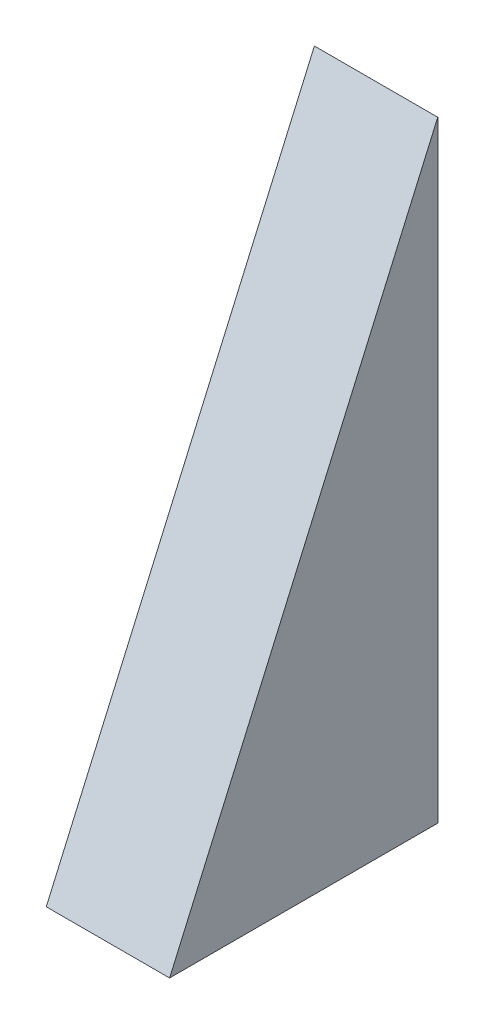
from build123d import *

# Parameters (mm, degrees)
BOSS_EXTRUDE1_DEPTH = 23


with BuildPart() as part:
    # Sketch1 → Boss-Extrude1 (new body)
    with BuildSketch(Plane(origin=(0, 0, 0), x_dir=(0, 0, -1), z_dir=(1, 0, 0))):
        Polygon((-90, -24.055372081), (-40, -24.055372081), (-40, 89.944627919), align=None)
    extrude(amount=BOSS_EXTRUDE1_DEPTH)


solid = part.part
